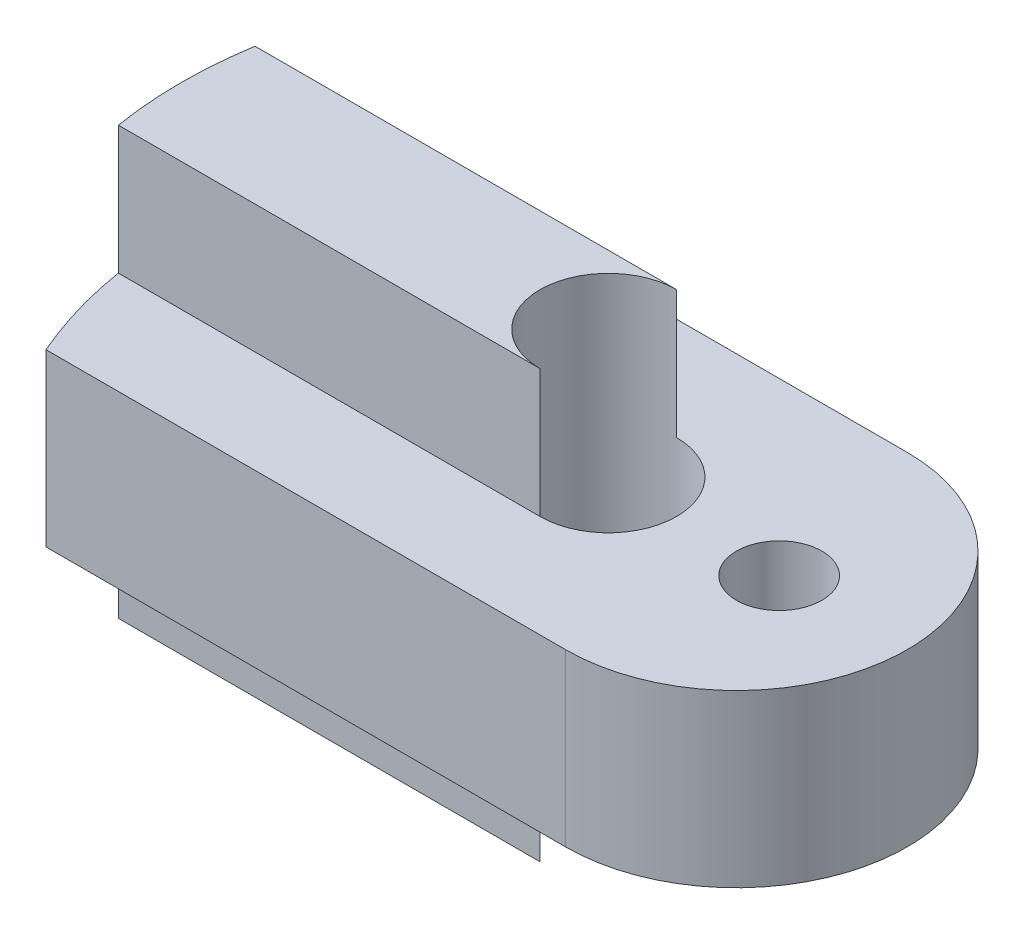
from build123d import *

# Parameters (mm, degrees)
BOSS_EXTRUDE3_DEPTH      = 10
BOSS_EXTRUDE5_DEPTH      = 2
BOSS_EXTRUDE5_DEPTH_BACK = 2
SKETCH4_R                = 1.6
CUT_EXTRUDE1_DEPTH       = 15.696938457
SKETCH5_R                = 1
CUT_EXTRUDE3_DEPTH       = 13.845232579


with BuildPart() as part:
    # Sketch2 → Boss-Extrude3 (new body)
    with BuildSketch(Plane(origin=(0, 0, 0), x_dir=(1, 0, 0), z_dir=(0, 1, 0))):
        with BuildLine():
            Line((0, -1.6), (-9.871170143, -1.6))
            ThreePointArc((-9.871170143, -1.6), (-10, 0), (-9.871170143, 1.6))
            Line((-9.871170143, 1.6), (0, 1.6))
            ThreePointArc((0, 1.6), (1.6, 0), (0, -1.6))
        make_face()
    extrude(amount=BOSS_EXTRUDE3_DEPTH)

    # Sketch3 → Boss-Extrude5 (add, two sides: drawn at the far end of the back side and taken through both)
    with BuildSketch(Plane(origin=(0, 5, 0), x_dir=(1, 0, 0), z_dir=(0, 1, 0)).offset(-BOSS_EXTRUDE5_DEPTH_BACK)):
        with BuildLine():
            Line((3, -4), (-9.16515139, -4))
            ThreePointArc((-9.16515139, -4), (-10, 0), (-9.16515139, 4))
            Line((-9.16515139, 4), (3, 4))
            ThreePointArc((3, 4), (7, 0), (3, -4))
        make_face()
    extrude(amount=BOSS_EXTRUDE5_DEPTH + BOSS_EXTRUDE5_DEPTH_BACK)

    # Sketch4 → Cut-Extrude1 (cut, through all)
    with BuildSketch(Plane(origin=(0, 10, 0), x_dir=(1, 0, 0), z_dir=(0, 1, 0))):
        Circle(SKETCH4_R)
    extrude(amount=-CUT_EXTRUDE1_DEPTH, mode=Mode.SUBTRACT)

    # Sketch5 → Cut-Extrude3 (cut, through all)
    with BuildSketch(Plane(origin=(0, 7, 0), x_dir=(1, 0, 0), z_dir=(0, 1, 0))):
        with Locations((4, 0)):
            Circle(SKETCH5_R)
    extrude(amount=-CUT_EXTRUDE3_DEPTH, mode=Mode.SUBTRACT)


solid = part.part
